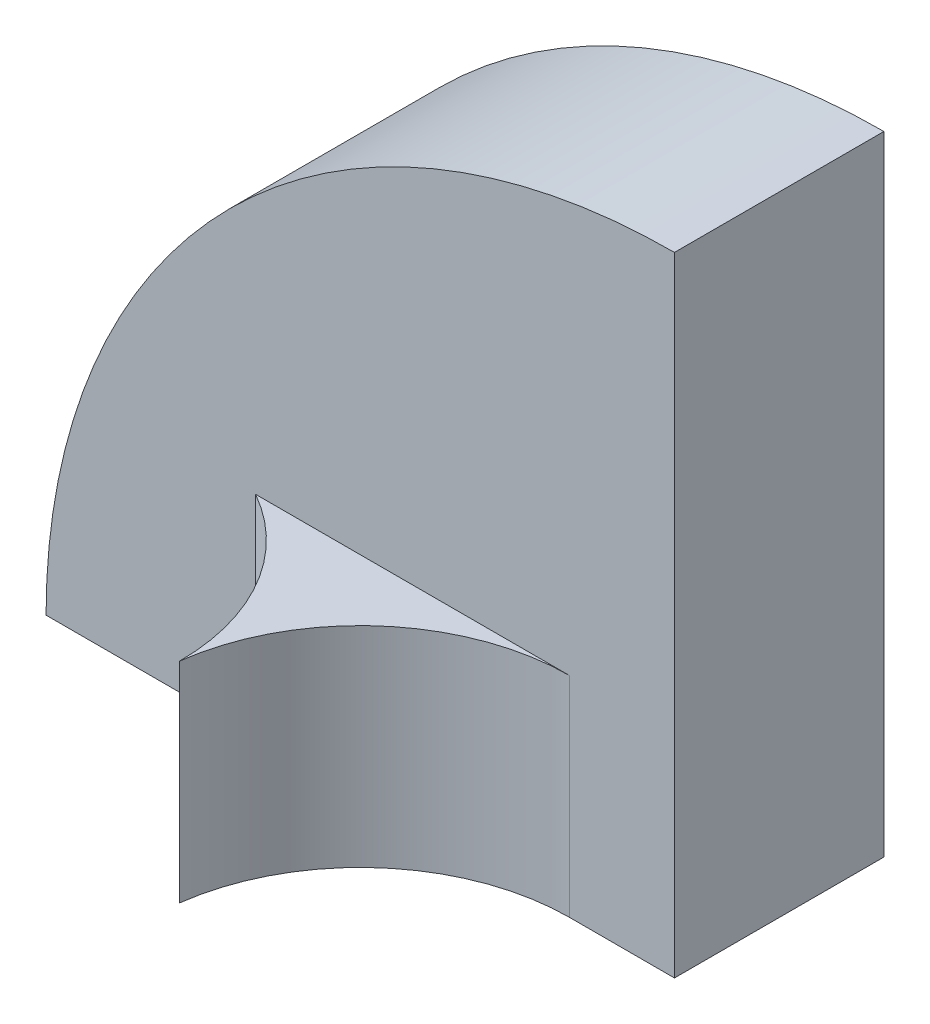
from build123d import *

# Parameters (mm, degrees)
BOSS_EXTRUDE1_DEPTH = 2
BOSS_EXTRUDE2_DEPTH = 2


with BuildPart() as part:
    # Sketch1 → Boss-Extrude1 (new body)
    with BuildSketch(Plane.XY):
        with BuildLine():
            Line((0, 0), (0, 6))
            ThreePointArc((0, 6), (-4.242640687, 4.242640687), (-6, 0))
            Line((-6, 0), (0, 0))
        make_face()
    extrude(amount=BOSS_EXTRUDE1_DEPTH)

    # Sketch2 → Boss-Extrude2 (add)
    with BuildSketch(Plane.XZ):
        with BuildLine():
            ThreePointArc((-2.983237378, 3.741602043), (-3.256022499, 2.733272353), (-3.999966142, 2))
            Line((-3.999966142, 2), (-1.000033858, 2))
            ThreePointArc((-1.000033858, 2), (-2.319710429, 2.497214459), (-2.983237378, 3.741602043))
        make_face()
    extrude(amount=-BOSS_EXTRUDE2_DEPTH)


solid = part.part
